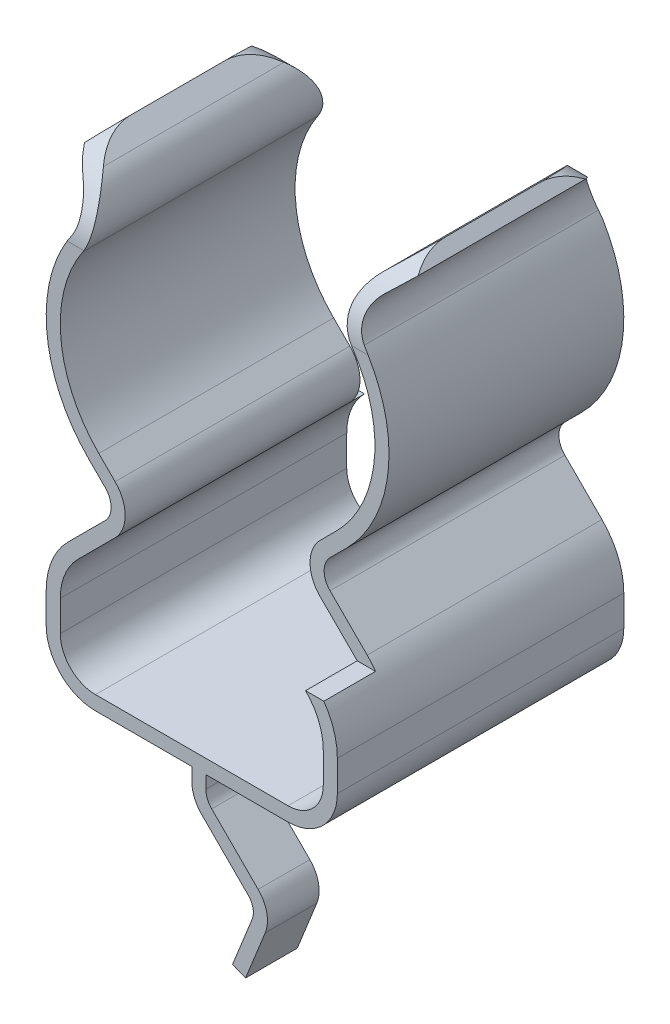
from build123d import *

# Parameters (mm, degrees)
EXTRU_MINCE1_DEPTH           = 3.05
ESQUISSE3_W                  = 5
ESQUISSE3_H                  = 3.328220353
ENL_V_MAT_EXTRU_1_DEPTH      = 10
R_P_TITION_CIRCULAIRE1_COUNT = 2


with BuildPart() as part:
    # Esquisse2 → Extru.-Mince1 (new, symmetric)
    with BuildSketch(Plane.XY):
        with BuildLine():
            Line((0.867691044, -3.516497462), (1.284684178, -2.477324095))
            ThreePointArc((1.284684178, -2.477324095), (1.304066655, -2.262192987), (1.201715788, -2.071978966))
            Line((1.201715788, -2.071978966), (0.211890589, -1.082153766))
            ThreePointArc((0.211890589, -1.082153766), (0.05506857, -0.847453029), (0, -0.570604633))
            Line((0, -0.570604633), (0, 0))
            Line((0, 0), (2.05, 0))
            ThreePointArc((2.05, 0), (2.580330086, 0.219669914), (2.8, 0.75))
            Line((2.8, 0.75), (2.8, 1.400152821))
            ThreePointArc((2.8, 1.400152821), (2.702061046, 1.892525191), (2.423154503, 2.309938332))
            Line((2.423154503, 2.309938332), (1.63248823, 3.100604604))
            ThreePointArc((1.63248823, 3.100604604), (1.418134189, 3.618101038), (1.63248823, 4.135597473))
            Line((1.63248823, 4.135597473), (1.979898987, 4.48300823))
            ThreePointArc((1.979898987, 4.48300823), (2.787260417, 6.196112604), (2.31953586, 8.031267314))
            ThreePointArc((2.31953586, 8.031267314), (2.164350637, 8.664278157), (2.458268281, 9.245997676))
            Line((2.458268281, 9.245997676), (2.8, 9.563603836))
            Line((2.8, 9.563603836), (3.004233324, 9.343856824))
            Line((3.004233324, 9.343856824), (2.662501605, 9.026250664))
            ThreePointArc((2.662501605, 9.026250664), (2.462413038, 8.630236925), (2.568057559, 8.199305896))
            ThreePointArc((2.568057559, 8.199305896), (3.085895462, 6.167527467), (2.192031022, 4.270876196))
            Line((2.192031022, 4.270876196), (1.844620265, 3.923465439))
            ThreePointArc((1.844620265, 3.923465439), (1.718134189, 3.618101038), (1.844620265, 3.312736638))
            Line((1.844620265, 3.312736638), (2.635286537, 2.522070366))
            ThreePointArc((2.635286537, 2.522070366), (2.979224906, 2.007330221), (3.1, 1.400152821))
            Line((3.1, 1.400152821), (3.1, 0.75))
            ThreePointArc((3.1, 0.75), (2.79246212, 0.00753788), (2.05, -0.3))
            Line((2.05, -0.3), (0.3, -0.3))
            Line((0.3, -0.3), (0.3, -0.570604633))
            ThreePointArc((0.3, -0.570604633), (0.33223243, -0.732648), (0.424022623, -0.870021732))
            Line((0.424022623, -0.870021732), (1.413847823, -1.859846932))
            ThreePointArc((1.413847823, -1.859846932), (1.597973034, -2.202034526), (1.563104716, -2.589046986))
            Line((1.563104716, -2.589046986), (1.146111581, -3.628220353))
            Line((1.146111581, -3.628220353), (0.867691044, -3.516497462))
        make_face()
    extru_mince1 = extrude(amount=EXTRU_MINCE1_DEPTH, both=True)

    # Esquisse3 → Enlèv. mat.-Extru.1 (cut)
    with BuildSketch(Plane(origin=(0, 0, 0), x_dir=(0, 0, -1), z_dir=(1, 0, 0))):
        with Locations((0.55, -1.964110177)):
            Rectangle(ESQUISSE3_W, ESQUISSE3_H)
        with BuildLine():
            Line((3.05, 9.563603836), (1.55, 9.563603836))
            ThreePointArc((1.55, 9.563603836), (2.610660172, 9.124264008), (3.05, 8.063603836))
            Line((3.05, 8.063603836), (3.05, 9.563603836))
        make_face()
        with BuildLine():
            Line((-0.45, 9.563603836), (-3.05, 9.563603836))
            Line((-3.05, 9.563603836), (-3.05, 2.309938332))
            Line((-3.05, 2.309938332), (-1.95, 2.309938332))
            Line((-1.95, 2.309938332), (-1.95, 8.063603836))
            ThreePointArc((-1.95, 8.063603836), (-1.510660172, 9.124264008), (-0.45, 9.563603836))
        make_face()
    enl_v_mat_extru_1 = extrude(amount=ENL_V_MAT_EXTRU_1_DEPTH, mode=Mode.SUBTRACT)

    # Répétition circulaire1: Extru.-Mince1, Enlèv. mat.-Extru.1 ×2 about axis
    r_p_tition_circulaire1_axis = Axis((0, -4.287811562, 0), (0, 1, 0))
    add([extru_mince1.rotate(r_p_tition_circulaire1_axis, i * 360 / R_P_TITION_CIRCULAIRE1_COUNT) for i in range(1, R_P_TITION_CIRCULAIRE1_COUNT)])
    add([enl_v_mat_extru_1.rotate(r_p_tition_circulaire1_axis, i * 360 / R_P_TITION_CIRCULAIRE1_COUNT) for i in range(1, R_P_TITION_CIRCULAIRE1_COUNT)], mode=Mode.SUBTRACT)


solid = part.part
